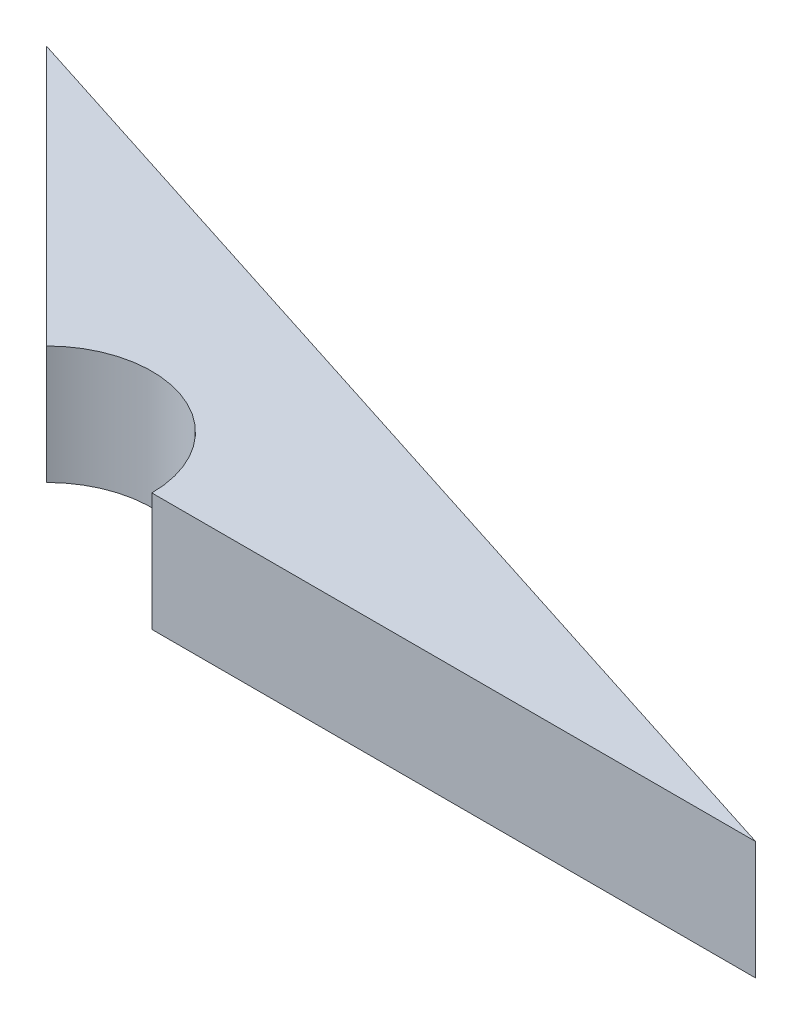
from build123d import *

# Parameters (mm, degrees)
BOSS_EXTRUDE1_DEPTH = 5


with BuildPart() as part:
    # Sketch1 → Boss-Extrude1 (new body)
    with BuildSketch(Plane(origin=(0, 0, 0), x_dir=(1, 0, 0), z_dir=(0, 1, 0))):
        with BuildLine():
            Line((-7.322989036, -0.368016894), (-32.862670249, -0.368016894))
            ThreePointArc((-32.862670249, -0.368016894), (-35.616098933, 3.752780342), (-40.476910696, 2.785904767))
            Line((-40.476910696, 2.785904767), (-51.46512466, 13.77411873))
            Line((-51.46512466, 13.77411873), (-7.322989036, -0.368016894))
        make_face()
    extrude(amount=BOSS_EXTRUDE1_DEPTH)


solid = part.part
